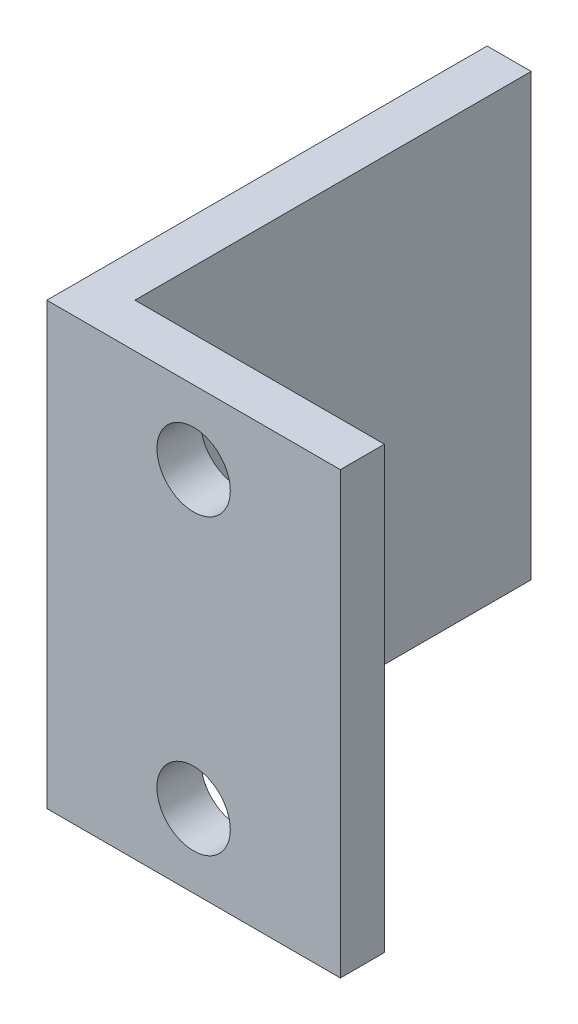
from build123d import *

# Parameters (mm, degrees)
BOSS_EXTRUDE1_DEPTH = 30
SKETCH2_R           = 2.5
CUT_EXTRUDE1_DEPTH  = 31


with BuildPart() as part:
    # Sketch1 → Boss-Extrude1 (new body)
    with BuildSketch(Plane(origin=(0, 0, 0), x_dir=(1, 0, 0), z_dir=(0, 1, 0))):
        Polygon((0, 30), (0, 0), (20, 0), (20, 3), (3, 3), (3, 30), align=None)
    extrude(amount=BOSS_EXTRUDE1_DEPTH)

    # Sketch2 → Cut-Extrude1 (cut, through all)
    with BuildSketch(Plane.XY):
        with Locations((10, 25)):
            Circle(SKETCH2_R)
        with Locations((10, 5)):
            Circle(SKETCH2_R)
    extrude(amount=-CUT_EXTRUDE1_DEPTH, mode=Mode.SUBTRACT)


solid = part.part
